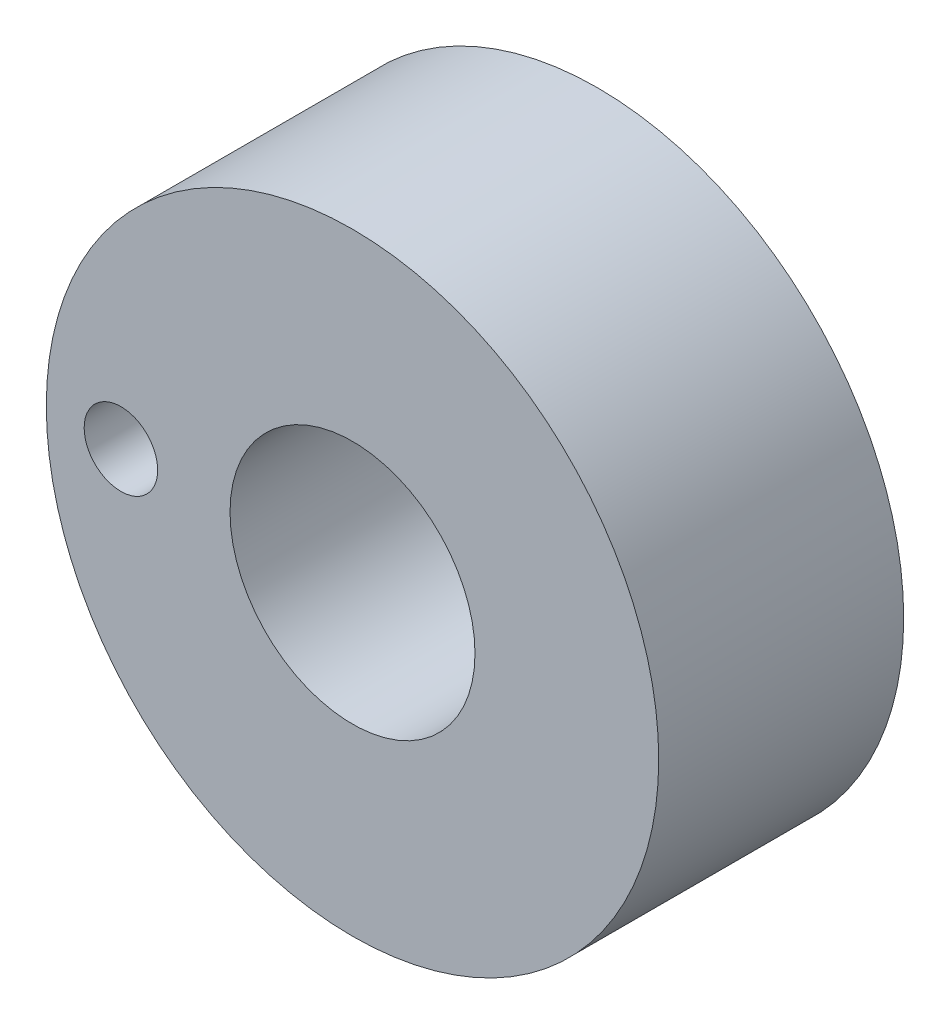
from build123d import *

# Parameters (mm, degrees)
SKETCH1_R           = 25
BOSS_EXTRUDE1_DEPTH = 20
SKETCH3_R           = 10
SKETCH3_R_2         = 3
CUT_EXTRUDE2_DEPTH  = 21


with BuildPart() as part:
    # Sketch1 → Boss-Extrude1 (new body)
    with BuildSketch(Plane.XY):
        Circle(SKETCH1_R)
    extrude(amount=BOSS_EXTRUDE1_DEPTH)

    # Sketch3 → Cut-Extrude2 (cut, through all)
    with BuildSketch(Plane(origin=(0, 0, 0), x_dir=(-1, 0, 0), z_dir=(0, 0, -1))):
        Circle(SKETCH3_R)
        with Locations((18.908249043, 0)):
            Circle(SKETCH3_R_2)
    extrude(amount=-CUT_EXTRUDE2_DEPTH, mode=Mode.SUBTRACT)


solid = part.part
